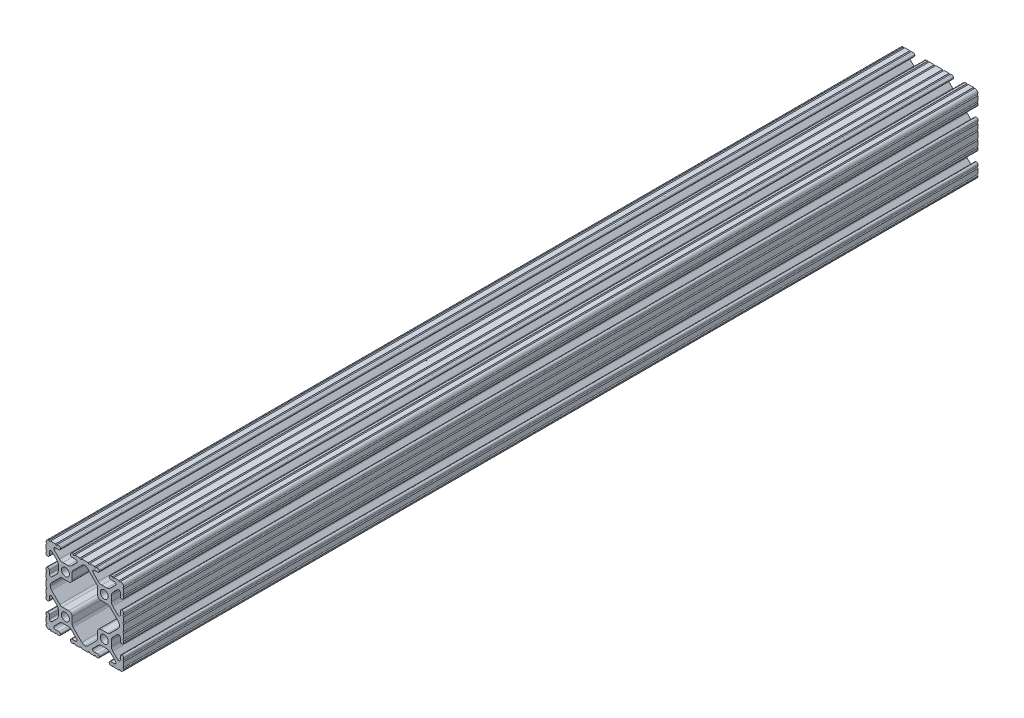
from build123d import *

# Parameters (mm, degrees)
SKETCH1_R           = 1.30175
BOSS_EXTRUDE1_DEPTH = 279.4


with BuildPart() as part:
    # Sketch1 → Boss-Extrude1 (new body)
    with BuildSketch(Plane(origin=(0, 0, -3683), x_dir=(-1, 0, 0), z_dir=(0, 0, -1))):
        with BuildLine():
            Line((-4.202565008, -12.7), (-3.72896307, -12.7))
            ThreePointArc((-3.72896307, -12.7), (-3.477864707, -12.407716686), (-3.226766344, -12.7))
            Line((-3.226766344, -12.7), (-1.607257984, -12.7))
            ThreePointArc((-1.607257984, -12.7), (-1.356159621, -12.407716686), (-1.105061258, -12.7))
            Line((-1.105061258, -12.7), (1.105061258, -12.7))
            ThreePointArc((1.105061258, -12.7), (1.356159621, -12.407716686), (1.607257984, -12.7))
            Line((1.607257984, -12.7), (3.226766344, -12.7))
            ThreePointArc((3.226766344, -12.7), (3.477864707, -12.407716686), (3.72896307, -12.7))
            Line((3.72896307, -12.7), (4.202565008, -12.7))
            ThreePointArc((4.202565008, -12.7), (4.575584585, -12.550181208), (4.730750011, -12.179353801))
            Line((4.730750011, -12.179353801), (4.730750011, -12.115746199))
            ThreePointArc((4.730750011, -12.115746199), (4.575584581, -11.744918788), (4.202564997, -11.5951))
            Line((4.202564997, -11.5951), (3.04387699, -11.5951))
            ThreePointArc((3.04387699, -11.5951), (2.586724299, -11.289640337), (2.693987468, -10.75039197))
            Line((2.693987468, -10.75039197), (4.381511453, -9.062867985))
            ThreePointArc((4.381511453, -9.062867985), (4.89653352, -8.718741242), (5.504043468, -8.5979))
            Line((5.504043468, -8.5979), (7.19595652, -8.5979))
            ThreePointArc((7.19595652, -8.5979), (7.803466469, -8.718741242), (8.318488536, -9.062867985))
            Line((8.318488536, -9.062867985), (10.006012521, -10.75039197))
            ThreePointArc((10.006012521, -10.75039197), (10.111867084, -11.293005867), (9.648826409, -11.595046199))
            Line((9.648826409, -11.595046199), (8.48995, -11.595046199))
            ThreePointArc((8.48995, -11.595046199), (8.121759499, -11.747555698), (7.96925, -12.115746199))
            Line((7.96925, -12.115746199), (7.96925, -12.179246199))
            ThreePointArc((7.96925, -12.179246199), (8.124377102, -12.550143437), (8.497434992, -12.7))
            Line((8.497434992, -12.7), (9.067007843, -12.7))
            ThreePointArc((9.067007843, -12.7), (9.318106206, -12.407716686), (9.569204568, -12.7))
            Line((9.569204568, -12.7), (11.206606606, -12.7))
            ThreePointArc((11.206606606, -12.7), (11.457704969, -12.407716686), (11.708803332, -12.7))
            Line((11.708803332, -12.7), (11.725039362, -12.7))
            ThreePointArc((11.725039362, -12.7), (12.419364767, -12.365032382), (12.7, -11.647024764))
            Line((12.7, -11.647024764), (12.7, -11.634324764))
            ThreePointArc((12.7, -11.634324764), (12.446, -11.380324764), (12.7, -11.126324764))
            Line((12.7, -11.126324764), (12.7, -9.512619678))
            ThreePointArc((12.7, -9.512619678), (12.446, -9.258619678), (12.7, -9.004619678))
            Line((12.7, -9.004619678), (12.7, -8.458020905))
            ThreePointArc((12.7, -8.458020905), (12.547490501, -8.089830404), (12.1793, -7.937320905))
            Line((12.1793, -7.937320905), (12.1158, -7.937320905))
            ThreePointArc((12.1158, -7.937320905), (11.747609499, -8.089830404), (11.5951, -8.458020905))
            Line((11.5951, -8.458020905), (11.5951, -9.550494395))
            ThreePointArc((11.5951, -9.550494395), (11.281503184, -10.019825197), (10.727889755, -9.909704639))
            Line((10.727889755, -9.909704639), (9.139067985, -8.320882869))
            ThreePointArc((9.139067985, -8.320882869), (8.794941242, -7.805860803), (8.6741, -7.198350854))
            Line((8.6741, -7.198350854), (8.6741, -5.501747521))
            ThreePointArc((8.6741, -5.501747521), (8.795305381, -4.893359207), (9.1404135, -4.377871602))
            Line((9.1404135, -4.377871602), (10.72832032, -2.793764621))
            ThreePointArc((10.72832032, -2.793764621), (11.28178426, -2.684190637), (11.5951, -3.153404915))
            Line((11.5951, -3.153404915), (11.5951, -4.241979095))
            ThreePointArc((11.5951, -4.241979095), (11.747609499, -4.610169596), (12.1158, -4.762679095))
            Line((12.1158, -4.762679095), (12.1793, -4.762679095))
            ThreePointArc((12.1793, -4.762679095), (12.547490501, -4.610169596), (12.7, -4.241979095))
            Line((12.7, -4.241979095), (12.7, -3.663843343))
            ThreePointArc((12.7, -3.663843343), (12.446, -3.409843343), (12.7, -3.155843343))
            Line((12.7, -3.155843343), (12.7, -1.542138256))
            ThreePointArc((12.7, -1.542138256), (12.446, -1.288138256), (12.7, -1.034138256))
            Line((12.7, -1.034138256), (12.7, 1.034138256))
            ThreePointArc((12.7, 1.034138256), (12.446, 1.288138256), (12.7, 1.542138256))
            Line((12.7, 1.542138256), (12.7, 3.155843343))
            ThreePointArc((12.7, 3.155843343), (12.446, 3.409843343), (12.7, 3.663843343))
            Line((12.7, 3.663843343), (12.7, 4.241979095))
            ThreePointArc((12.7, 4.241979095), (12.547490501, 4.610169596), (12.1793, 4.762679095))
            Line((12.1793, 4.762679095), (12.1158, 4.762679095))
            ThreePointArc((12.1158, 4.762679095), (11.747609499, 4.610169596), (11.5951, 4.241979095))
            Line((11.5951, 4.241979095), (11.5951, 3.153404915))
            ThreePointArc((11.5951, 3.153404915), (11.28178426, 2.684190637), (10.72832032, 2.793764621))
            Line((10.72832032, 2.793764621), (9.1404135, 4.377871602))
            ThreePointArc((9.1404135, 4.377871602), (8.795305381, 4.893359207), (8.6741, 5.501747521))
            Line((8.6741, 5.501747521), (8.6741, 7.198350854))
            ThreePointArc((8.6741, 7.198350854), (8.794941242, 7.805860803), (9.139067985, 8.320882869))
            Line((9.139067985, 8.320882869), (10.727889755, 9.909704639))
            ThreePointArc((10.727889755, 9.909704639), (11.281503184, 10.019825197), (11.5951, 9.550494395))
            Line((11.5951, 9.550494395), (11.5951, 8.458020905))
            ThreePointArc((11.5951, 8.458020905), (11.747609499, 8.089830404), (12.1158, 7.937320905))
            Line((12.1158, 7.937320905), (12.1793, 7.937320905))
            ThreePointArc((12.1793, 7.937320905), (12.547490501, 8.089830404), (12.7, 8.458020905))
            Line((12.7, 8.458020905), (12.7, 9.004619678))
            ThreePointArc((12.7, 9.004619678), (12.446, 9.258619678), (12.7, 9.512619678))
            Line((12.7, 9.512619678), (12.7, 11.126324764))
            ThreePointArc((12.7, 11.126324764), (12.446, 11.380324764), (12.7, 11.634324764))
            Line((12.7, 11.634324764), (12.7, 11.647024764))
            ThreePointArc((12.7, 11.647024764), (12.419364767, 12.365032382), (11.725039362, 12.7))
            Line((11.725039362, 12.7), (11.708803332, 12.7))
            ThreePointArc((11.708803332, 12.7), (11.457704969, 12.407716686), (11.206606606, 12.7))
            Line((11.206606606, 12.7), (9.569204568, 12.7))
            ThreePointArc((9.569204568, 12.7), (9.318106206, 12.407716686), (9.067007843, 12.7))
            Line((9.067007843, 12.7), (8.497434992, 12.7))
            ThreePointArc((8.497434992, 12.7), (8.124377102, 12.550143437), (7.96925, 12.179246199))
            Line((7.96925, 12.179246199), (7.96925, 12.115746199))
            ThreePointArc((7.96925, 12.115746199), (8.121759499, 11.747555698), (8.48995, 11.595046199))
            Line((8.48995, 11.595046199), (9.648826409, 11.595046199))
            ThreePointArc((9.648826409, 11.595046199), (10.111867084, 11.293005867), (10.006012521, 10.75039197))
            Line((10.006012521, 10.75039197), (8.318488536, 9.062867985))
            ThreePointArc((8.318488536, 9.062867985), (7.803466469, 8.718741242), (7.19595652, 8.5979))
            Line((7.19595652, 8.5979), (5.504043468, 8.5979))
            ThreePointArc((5.504043468, 8.5979), (4.89653352, 8.718741242), (4.381511453, 9.062867985))
            Line((4.381511453, 9.062867985), (2.693987468, 10.75039197))
            ThreePointArc((2.693987468, 10.75039197), (2.586724299, 11.289640337), (3.04387699, 11.5951))
            Line((3.04387699, 11.5951), (4.202564997, 11.5951))
            ThreePointArc((4.202564997, 11.5951), (4.575584581, 11.744918788), (4.730750011, 12.115746199))
            Line((4.730750011, 12.115746199), (4.730750011, 12.179353801))
            ThreePointArc((4.730750011, 12.179353801), (4.575584585, 12.550181208), (4.202565008, 12.7))
            Line((4.202565008, 12.7), (3.72896307, 12.7))
            ThreePointArc((3.72896307, 12.7), (3.477864707, 12.407716686), (3.226766344, 12.7))
            Line((3.226766344, 12.7), (1.607257984, 12.7))
            ThreePointArc((1.607257984, 12.7), (1.356159621, 12.407716686), (1.105061258, 12.7))
            Line((1.105061258, 12.7), (-1.105061258, 12.7))
            ThreePointArc((-1.105061258, 12.7), (-1.356159621, 12.407716686), (-1.607257984, 12.7))
            Line((-1.607257984, 12.7), (-3.226766344, 12.7))
            ThreePointArc((-3.226766344, 12.7), (-3.477864707, 12.407716686), (-3.72896307, 12.7))
            Line((-3.72896307, 12.7), (-4.202565008, 12.7))
            ThreePointArc((-4.202565008, 12.7), (-4.575584585, 12.550181208), (-4.730750011, 12.179353801))
            Line((-4.730750011, 12.179353801), (-4.730750011, 12.115746199))
            ThreePointArc((-4.730750011, 12.115746199), (-4.575584589, 11.744918797), (-4.202565019, 11.5951))
            Line((-4.202565019, 11.5951), (-3.043877004, 11.5951))
            ThreePointArc((-3.043877004, 11.5951), (-2.586724311, 11.289640337), (-2.693987481, 10.750391969))
            Line((-2.693987481, 10.750391969), (-4.381511464, 9.062867985))
            ThreePointArc((-4.381511464, 9.062867985), (-4.896533531, 8.718741242), (-5.50404348, 8.5979))
            Line((-5.50404348, 8.5979), (-7.19595652, 8.5979))
            ThreePointArc((-7.19595652, 8.5979), (-7.803466469, 8.718741242), (-8.318488536, 9.062867985))
            Line((-8.318488536, 9.062867985), (-10.006012521, 10.75039197))
            ThreePointArc((-10.006012521, 10.75039197), (-10.111867084, 11.293005867), (-9.648826409, 11.595046199))
            Line((-9.648826409, 11.595046199), (-8.48995, 11.595046199))
            ThreePointArc((-8.48995, 11.595046199), (-8.121759499, 11.747555698), (-7.96925, 12.115746199))
            Line((-7.96925, 12.115746199), (-7.96925, 12.179246199))
            ThreePointArc((-7.96925, 12.179246199), (-8.124377102, 12.550143437), (-8.497434992, 12.7))
            Line((-8.497434992, 12.7), (-9.067007843, 12.7))
            ThreePointArc((-9.067007843, 12.7), (-9.318106206, 12.407716686), (-9.569204568, 12.7))
            Line((-9.569204568, 12.7), (-11.206606606, 12.7))
            ThreePointArc((-11.206606606, 12.7), (-11.457704969, 12.407716686), (-11.708803332, 12.7))
            Line((-11.708803332, 12.7), (-11.725039362, 12.7))
            ThreePointArc((-11.725039362, 12.7), (-12.419364767, 12.365032382), (-12.7, 11.647024764))
            Line((-12.7, 11.647024764), (-12.7, 11.634324764))
            ThreePointArc((-12.7, 11.634324764), (-12.446, 11.380324764), (-12.7, 11.126324764))
            Line((-12.7, 11.126324764), (-12.7, 9.512619678))
            ThreePointArc((-12.7, 9.512619678), (-12.446, 9.258619678), (-12.7, 9.004619678))
            Line((-12.7, 9.004619678), (-12.7, 8.458020905))
            ThreePointArc((-12.7, 8.458020905), (-12.547490501, 8.089830404), (-12.1793, 7.937320905))
            Line((-12.1793, 7.937320905), (-12.1158, 7.937320905))
            ThreePointArc((-12.1158, 7.937320905), (-11.747609499, 8.089830404), (-11.5951, 8.458020905))
            Line((-11.5951, 8.458020905), (-11.5951, 9.550494395))
            ThreePointArc((-11.5951, 9.550494395), (-11.281503184, 10.019825197), (-10.727889755, 9.909704639))
            Line((-10.727889755, 9.909704639), (-9.139067985, 8.320882869))
            ThreePointArc((-9.139067985, 8.320882869), (-8.794941242, 7.805860803), (-8.6741, 7.198350854))
            Line((-8.6741, 7.198350854), (-8.6741, 5.501747521))
            ThreePointArc((-8.6741, 5.501747521), (-8.795305381, 4.893359207), (-9.1404135, 4.377871602))
            Line((-9.1404135, 4.377871602), (-10.72832032, 2.793764621))
            ThreePointArc((-10.72832032, 2.793764621), (-11.28178426, 2.684190637), (-11.5951, 3.153404915))
            Line((-11.5951, 3.153404915), (-11.5951, 4.241979095))
            ThreePointArc((-11.5951, 4.241979095), (-11.747609499, 4.610169596), (-12.1158, 4.762679095))
            Line((-12.1158, 4.762679095), (-12.1793, 4.762679095))
            ThreePointArc((-12.1793, 4.762679095), (-12.547490501, 4.610169596), (-12.7, 4.241979095))
            Line((-12.7, 4.241979095), (-12.7, 3.663843343))
            ThreePointArc((-12.7, 3.663843343), (-12.446, 3.409843343), (-12.7, 3.155843343))
            Line((-12.7, 3.155843343), (-12.7, 1.542138256))
            ThreePointArc((-12.7, 1.542138256), (-12.446, 1.288138256), (-12.7, 1.034138256))
            Line((-12.7, 1.034138256), (-12.7, -1.034138256))
            ThreePointArc((-12.7, -1.034138256), (-12.446, -1.288138256), (-12.7, -1.542138256))
            Line((-12.7, -1.542138256), (-12.7, -3.155843343))
            ThreePointArc((-12.7, -3.155843343), (-12.446, -3.409843343), (-12.7, -3.663843343))
            Line((-12.7, -3.663843343), (-12.7, -4.241979095))
            ThreePointArc((-12.7, -4.241979095), (-12.547490501, -4.610169596), (-12.1793, -4.762679095))
            Line((-12.1793, -4.762679095), (-12.1158, -4.762679095))
            ThreePointArc((-12.1158, -4.762679095), (-11.747609499, -4.610169596), (-11.5951, -4.241979095))
            Line((-11.5951, -4.241979095), (-11.5951, -3.153404915))
            ThreePointArc((-11.5951, -3.153404915), (-11.28178426, -2.684190637), (-10.72832032, -2.793764621))
            Line((-10.72832032, -2.793764621), (-9.1404135, -4.377871602))
            ThreePointArc((-9.1404135, -4.377871602), (-8.795305381, -4.893359207), (-8.6741, -5.501747521))
            Line((-8.6741, -5.501747521), (-8.6741, -7.198350854))
            ThreePointArc((-8.6741, -7.198350854), (-8.794941242, -7.805860803), (-9.139067985, -8.320882869))
            Line((-9.139067985, -8.320882869), (-10.727889755, -9.909704639))
            ThreePointArc((-10.727889755, -9.909704639), (-11.281503184, -10.019825197), (-11.5951, -9.550494395))
            Line((-11.5951, -9.550494395), (-11.5951, -8.458020905))
            ThreePointArc((-11.5951, -8.458020905), (-11.747609499, -8.089830404), (-12.1158, -7.937320905))
            Line((-12.1158, -7.937320905), (-12.1793, -7.937320905))
            ThreePointArc((-12.1793, -7.937320905), (-12.547490501, -8.089830404), (-12.7, -8.458020905))
            Line((-12.7, -8.458020905), (-12.7, -9.004619678))
            ThreePointArc((-12.7, -9.004619678), (-12.446, -9.258619678), (-12.7, -9.512619678))
            Line((-12.7, -9.512619678), (-12.7, -11.126324764))
            ThreePointArc((-12.7, -11.126324764), (-12.446, -11.380324764), (-12.7, -11.634324764))
            Line((-12.7, -11.634324764), (-12.7, -11.647024764))
            ThreePointArc((-12.7, -11.647024764), (-12.419364767, -12.365032382), (-11.725039362, -12.7))
            Line((-11.725039362, -12.7), (-11.708803332, -12.7))
            ThreePointArc((-11.708803332, -12.7), (-11.457704969, -12.407716686), (-11.206606606, -12.7))
            Line((-11.206606606, -12.7), (-9.569204568, -12.7))
            ThreePointArc((-9.569204568, -12.7), (-9.318106206, -12.407716686), (-9.067007843, -12.7))
            Line((-9.067007843, -12.7), (-8.497434992, -12.7))
            ThreePointArc((-8.497434992, -12.7), (-8.124377102, -12.550143437), (-7.96925, -12.179246199))
            Line((-7.96925, -12.179246199), (-7.96925, -12.115746199))
            ThreePointArc((-7.96925, -12.115746199), (-8.121759499, -11.747555698), (-8.48995, -11.595046199))
            Line((-8.48995, -11.595046199), (-9.648826409, -11.595046199))
            ThreePointArc((-9.648826409, -11.595046199), (-10.111867084, -11.293005867), (-10.006012521, -10.75039197))
            Line((-10.006012521, -10.75039197), (-8.318488536, -9.062867985))
            ThreePointArc((-8.318488536, -9.062867985), (-7.803466469, -8.718741242), (-7.19595652, -8.5979))
            Line((-7.19595652, -8.5979), (-5.50404348, -8.5979))
            ThreePointArc((-5.50404348, -8.5979), (-4.896533531, -8.718741242), (-4.381511464, -9.062867985))
            Line((-4.381511464, -9.062867985), (-2.693987481, -10.750391969))
            ThreePointArc((-2.693987481, -10.750391969), (-2.586724311, -11.289640337), (-3.043877004, -11.5951))
            Line((-3.043877004, -11.5951), (-4.202565019, -11.5951))
            ThreePointArc((-4.202565019, -11.5951), (-4.575584589, -11.744918797), (-4.730750011, -12.115746199))
            Line((-4.730750011, -12.115746199), (-4.730750011, -12.179353801))
            ThreePointArc((-4.730750011, -12.179353801), (-4.575584585, -12.550181208), (-4.202565008, -12.7))
        make_face()
        with Locations((-6.35, -6.35)):
            Circle(SKETCH1_R, mode=Mode.SUBTRACT)
        with Locations((6.35, -6.35)):
            Circle(SKETCH1_R, mode=Mode.SUBTRACT)
        with Locations((6.35, 6.35)):
            Circle(SKETCH1_R, mode=Mode.SUBTRACT)
        with Locations((-6.35, 6.35)):
            Circle(SKETCH1_R, mode=Mode.SUBTRACT)
        with BuildLine():
            Line((3.841982283, -8.039832602), (0.99388543, -10.887929454))
            ThreePointArc((0.99388543, -10.887929454), (0.537960885, -11.196973583), (0, -11.315183353))
            ThreePointArc((0, -11.315183353), (-0.537960885, -11.196973583), (-0.99388543, -10.887929454))
            Line((-0.99388543, -10.887929454), (-3.841982283, -8.039832602))
            ThreePointArc((-3.841982283, -8.039832602), (-4.081494495, -7.681377244), (-4.1656, -7.258550319))
            Line((-4.1656, -7.258550319), (-4.1656, -5.1943))
            ThreePointArc((-4.1656, -5.1943), (-4.489217717, -4.413017717), (-5.2705, -4.0894))
            Line((-5.2705, -4.0894), (-7.408247879, -4.0894))
            ThreePointArc((-7.408247879, -4.0894), (-7.83046331, -4.00554757), (-8.188593683, -3.76671764))
            Line((-8.188593683, -3.76671764), (-10.88669158, -1.075076254))
            ThreePointArc((-10.88669158, -1.075076254), (-11.204191049, -0.600827657), (-11.3157, -0.041110408))
            Line((-11.3157, -0.041110408), (-11.3157, 0.041110408))
            ThreePointArc((-11.3157, 0.041110408), (-11.204191049, 0.600827657), (-10.88669158, 1.075076254))
            Line((-10.88669158, 1.075076254), (-8.188377048, 3.766933757))
            ThreePointArc((-8.188377048, 3.766933757), (-7.830246674, 4.005763687), (-7.408031244, 4.089616117))
            Line((-7.408031244, 4.089616117), (-5.2705, 4.089616117))
            ThreePointArc((-5.2705, 4.089616117), (-4.489217717, 4.413233834), (-4.1656, 5.194516117))
            Line((-4.1656, 5.194516117), (-4.1656, 7.258550319))
            ThreePointArc((-4.1656, 7.258550319), (-4.081494495, 7.681377244), (-3.841982283, 8.039832602))
            Line((-3.841982283, 8.039832602), (-0.897778744, 10.984036141))
            ThreePointArc((-0.897778744, 10.984036141), (-0.48576624, 11.273339484), (0, 11.405558575))
            ThreePointArc((0, 11.405558575), (0.48576624, 11.273339484), (0.897778744, 10.984036141))
            Line((0.897778744, 10.984036141), (3.841982283, 8.039832602))
            ThreePointArc((3.841982283, 8.039832602), (4.081494495, 7.681377244), (4.1656, 7.258550319))
            Line((4.1656, 7.258550319), (4.1656, 5.1943))
            ThreePointArc((4.1656, 5.1943), (4.489217717, 4.413017717), (5.2705, 4.0894))
            Line((5.2705, 4.0894), (7.408247879, 4.0894))
            ThreePointArc((7.408247879, 4.0894), (7.83046331, 4.00554757), (8.188593683, 3.76671764))
            Line((8.188593683, 3.76671764), (10.88669158, 1.075076254))
            ThreePointArc((10.88669158, 1.075076254), (11.204191049, 0.600827657), (11.3157, 0.041110408))
            Line((11.3157, 0.041110408), (11.3157, -0.041110408))
            ThreePointArc((11.3157, -0.041110408), (11.204191049, -0.600827657), (10.88669158, -1.075076254))
            Line((10.88669158, -1.075076254), (8.188593683, -3.76671764))
            ThreePointArc((8.188593683, -3.76671764), (7.83046331, -4.00554757), (7.408247879, -4.0894))
            Line((7.408247879, -4.0894), (5.2705, -4.0894))
            ThreePointArc((5.2705, -4.0894), (4.489217717, -4.413017717), (4.1656, -5.1943))
            Line((4.1656, -5.1943), (4.1656, -7.258550319))
            ThreePointArc((4.1656, -7.258550319), (4.081494495, -7.681377244), (3.841982283, -8.039832602))
        make_face(mode=Mode.SUBTRACT)
    extrude(amount=-BOSS_EXTRUDE1_DEPTH)


solid = part.part
